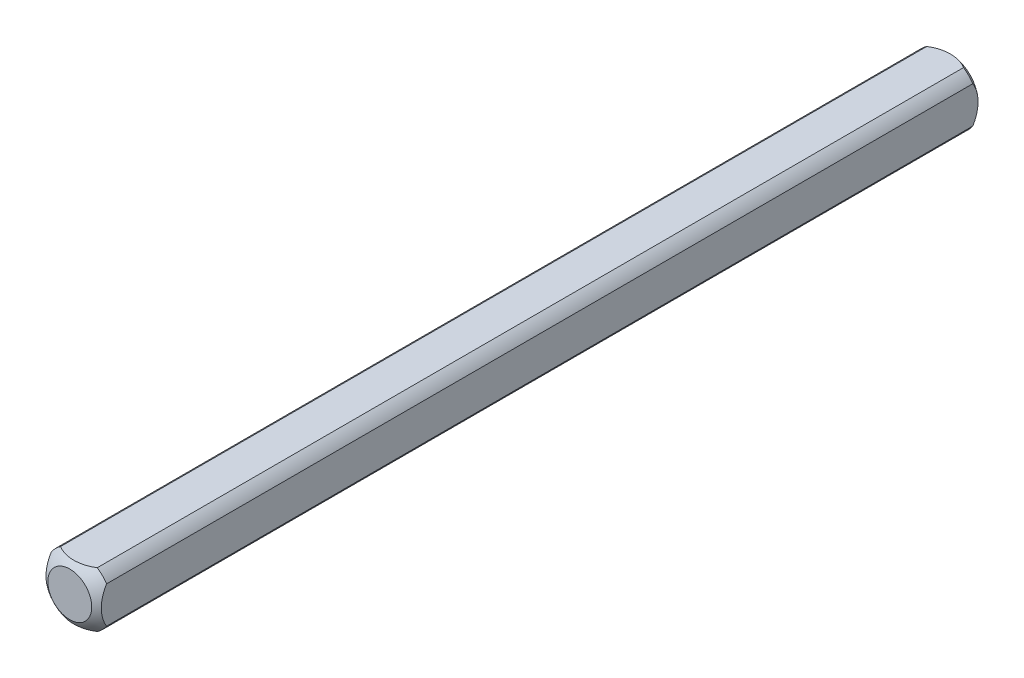
from build123d import *

# Parameters (mm, degrees)
SKETCH1_W           = 6.35
SKETCH1_H           = 6.35
BOSS_EXTRUDE1_DEPTH = 50.8
SKETCH2_OUTSIDE_W   = 18.668
SKETCH2_OUTSIDE_H   = 18.668
SKETCH2_OUTSIDE_R   = 3.81
CUT_EXTRUDE1_DEPTH  = 51.8


with BuildPart() as part:
    # Sketch1 → Boss-Extrude1 (new body)
    with BuildSketch(Plane.XY):
        Rectangle(SKETCH1_W, SKETCH1_H)
    extrude(amount=BOSS_EXTRUDE1_DEPTH)

    # Sketch2 outside → Cut-Extrude1 (cut, through all)
    with BuildSketch(Plane(origin=(0, 0, 0), x_dir=(-1, 0, 0), z_dir=(0, 0, -1))):
        Rectangle(SKETCH2_OUTSIDE_W, SKETCH2_OUTSIDE_H)
        Circle(SKETCH2_OUTSIDE_R, mode=Mode.SUBTRACT)
    extrude(amount=-CUT_EXTRUDE1_DEPTH, mode=Mode.SUBTRACT)

    # Sketch3 → Cut-Revolve1 (revolve, cut)
    with BuildSketch(Plane(origin=(0, 0, 0), x_dir=(1, 0, 0), z_dir=(0, 1, 0))):
        with BuildLine():
            Line((-5.053685963, -3.893335876), (-5.053685963, 5.740530545))
            Line((-5.053685963, 5.740530545), (0, 5.740530545))
            Line((0, 5.740530545), (0, 0.670274551))
            ThreePointArc((0, 0.670274551), (-3.404639553, -0.639469554), (-5.053685963, -3.893335876))
        make_face()
    revolve(axis=Axis((0, 0, 50.8), (0, 0, -1)), mode=Mode.SUBTRACT)

    # Mirror1: part across plane


with BuildPart() as part_1:
    add(part.part)
    add(part.part.mirror(Plane(origin=(0, 0, 50.8), x_dir=(1, 0, 0), z_dir=(0, 0, -1))))


solid = part_1.part
